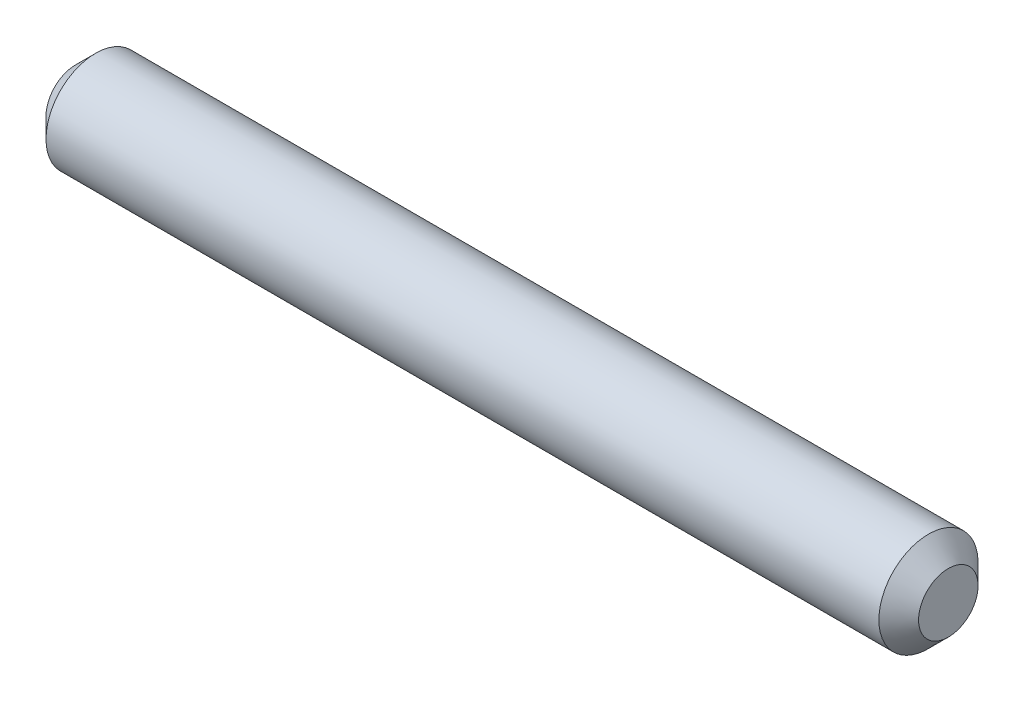
from build123d import *


with BuildPart() as part:
    # Szkic1 → Obrót1 (revolve)
    with BuildSketch(Plane.XY):
        Polygon((0, 1.5), (1, 2.5), (43, 2.5), (44, 1.5), (44, 0), (0, 0), align=None)
    revolve(axis=Axis((0, 0, 0), (1, 0, 0)))


solid = part.part
